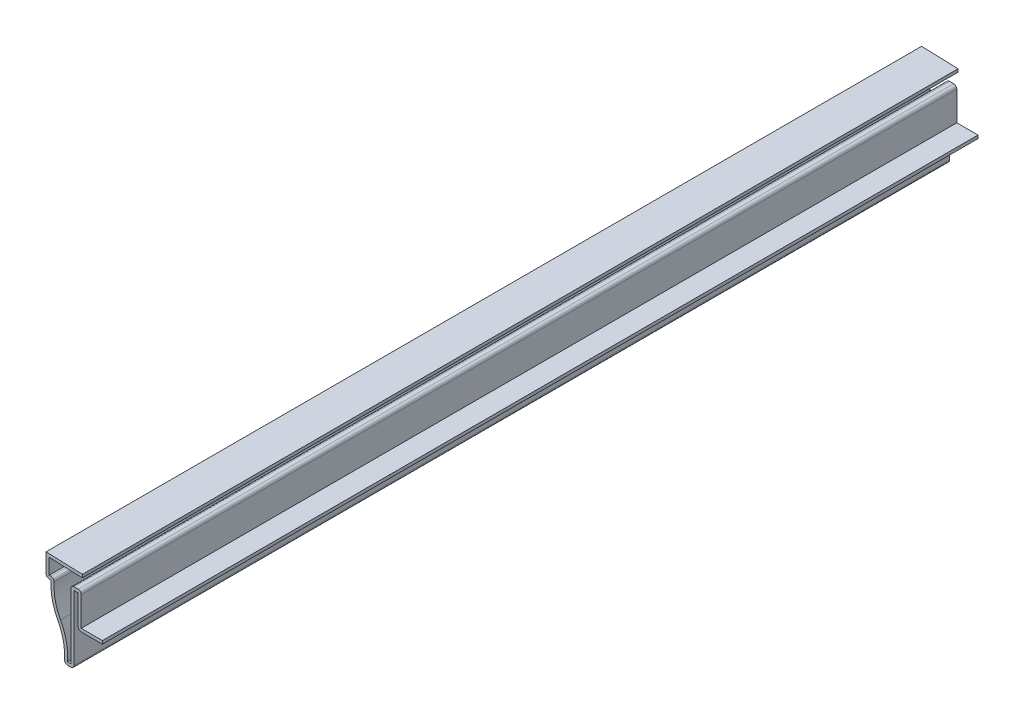
from build123d import *

# Parameters (mm, degrees)
BOSS_EXTRUDE1_DEPTH = 285.75
FILLET1_R           = 1.016


with BuildPart() as part:
    # Sketch1 → Boss-Extrude1 (new body)
    with BuildSketch(Plane.XY):
        with BuildLine():
            Line((0, 0), (0, 22.225))
            Line((0, 22.225), (1.3462, 22.225))
            Line((1.3462, 22.225), (1.3462, 11.684))
            Line((1.3462, 11.684), (9.2837, 11.684))
            Line((9.2837, 11.684), (9.2837, 12.7))
            Line((9.2837, 12.7), (2.3622, 12.7))
            Line((2.3622, 12.7), (2.3622, 23.241))
            Line((2.3622, 23.241), (-1.016, 23.241))
            Line((-1.016, 23.241), (-1.016, 1.016))
            Line((-1.016, 1.016), (-2.063377597, 1.016))
            ThreePointArc((-2.063377597, 1.016), (-2.48529022, 6.527253883), (-4.39485769, 11.714303305))
            ThreePointArc((-4.39485769, 11.714303305), (-6.222056703, 16.926496827), (-6.386074797, 22.44725))
            Line((-6.386074797, 22.44725), (-8.112125, 22.44725))
            Line((-8.112125, 22.44725), (-8.112125, 27.524569046))
            Line((-8.112125, 27.524569046), (2.744277132, 27.162688975))
            Line((2.744277132, 27.162688975), (2.778125, 28.178125))
            Line((2.778125, 28.178125), (-9.128125, 28.575))
            Line((-9.128125, 28.575), (-9.128125, 21.43125))
            Line((-9.128125, 21.43125), (-7.501829835, 21.43125))
            ThreePointArc((-7.501829835, 21.43125), (-7.107934178, 16.178984322), (-5.290870799, 11.235328872))
            ThreePointArc((-5.290870799, 11.235328872), (-3.370198099, 5.780137709), (-3.175, 0))
            Line((-3.175, 0), (0, 0))
        make_face()
    extrude(amount=-BOSS_EXTRUDE1_DEPTH)

    # Fillet1
    fillet1_edges = [part.edges().sort_by_distance(p)[0] for p in [
        (-3.175, 0, -142.875),
        (-9.128125, 21.43125, -142.875),
        (-6.386074797, 22.44725, -142.875),
        (-1.016, 23.241, -142.875),
        (2.3622, 23.241, -142.875),
        (1.3462, 11.684, -142.875),
        (0, 0, -142.875),
    ]]
    fillet(fillet1_edges, radius=FILLET1_R)


solid = part.part
